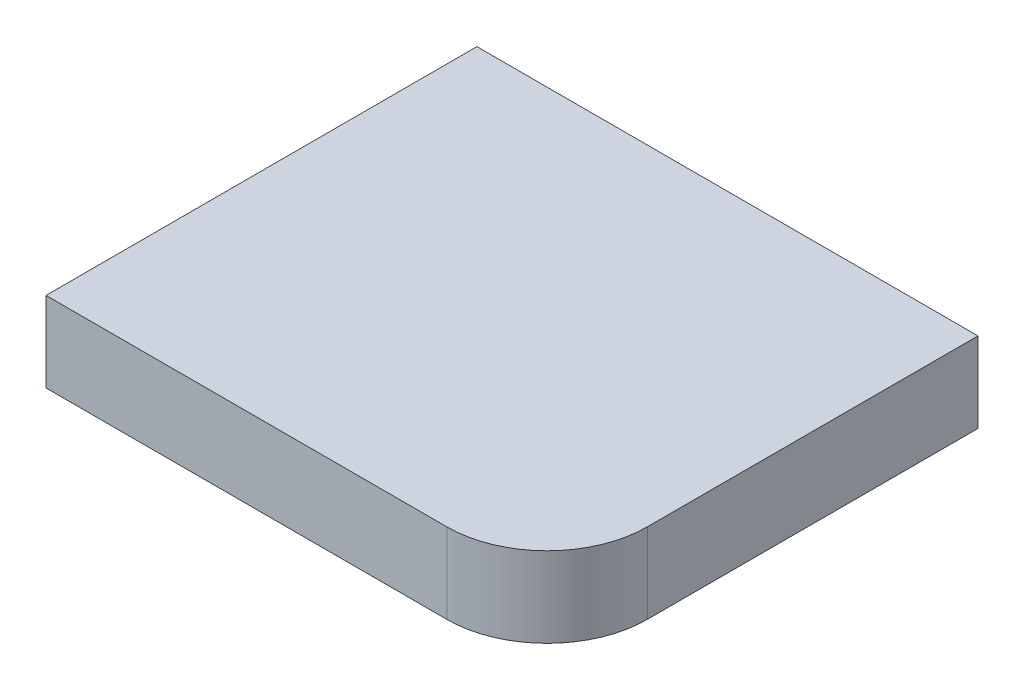
from build123d import *

# Parameters (mm, degrees)
EXTRUDE_1_DEPTH = 8


with BuildPart() as part:
    # Эскиз1 → Бобышка-Вытянуть1 (new body)
    with BuildSketch(Plane(origin=(0, 0, 0), x_dir=(1, 0, 0), z_dir=(0, 1, 0))):
        with BuildLine():
            Line((-25, -21.5), (15, -21.5))
            ThreePointArc((15, -21.5), (22.071067812, -18.571067812), (25, -11.5))
            Line((25, -11.5), (25, 21.5))
            Line((25, 21.5), (-25, 21.5))
            Line((-25, 21.5), (-25, -21.5))
        make_face()
    extrude(amount=EXTRUDE_1_DEPTH)


solid = part.part
